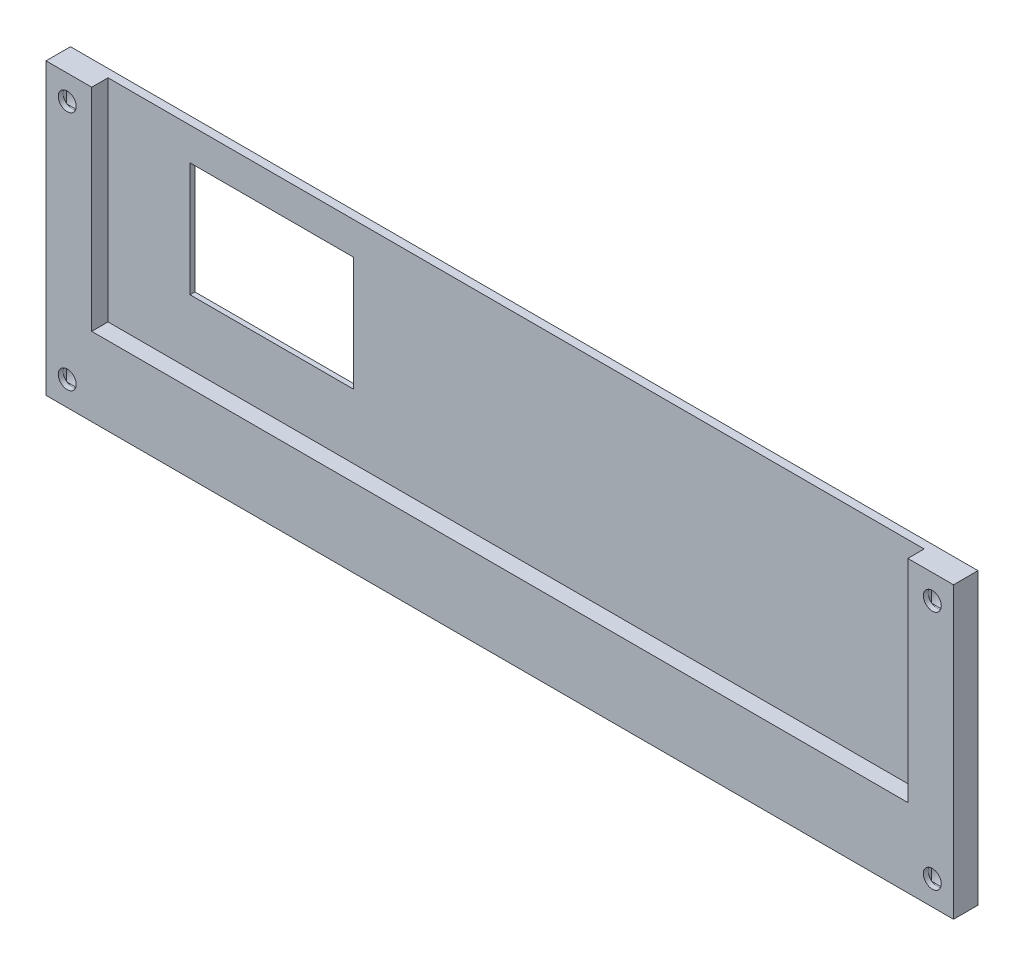
from build123d import *

# Parameters (mm, degrees)
SKETCH1_W                       = 112
SKETCH1_H                       = 35.5
BOSS_EXTRUDE1_DEPTH             = 1
SKETCH2_W                       = 6
SKETCH2_H                       = 6
BOSS_EXTRUDE2_DEPTH             = 2
SKETCH3_R                       = 1.1
CUT_EXTRUDE1_DEPTH              = 4
SKETCH4_R                       = 2
CUT_EXTRUDE2_DEPTH              = 2
SKETCH5_W                       = 20
SKETCH5_H                       = 14
CUT_EXTRUDE3_DEPTH              = 4
CHAMFER1_SIZE                   = 0.4
CUT_EXTRUDE4_DEPTH              = 0.2
SKETCH7_W                       = 2.2
SKETCH7_H                       = 2.2
CUT_EXTRUDE5_DEPTH              = 0.2
MIRROR2_COPY_1_DEPTH            = 0.2
MIRROR2_COPY_2_SKETCH_W         = 2.2
MIRROR2_COPY_2_SKETCH_H         = 2.2
MIRROR2_COPY_2_DEPTH            = 0.2
SKETCH8_W                       = 0.4
SKETCH8_H                       = 35.5
CUT_EXTRUDE6_DEPTH              = 3
CUT_EXTRUDE6_DEPTH_BACK         = 2
SKIZZE1_W                       = 5.6
SKIZZE1_H                       = 23.5
AUFSATZ_LINEAR_AUSTRAGEN1_DEPTH = 2


with BuildPart() as part:
    # Sketch1 → Boss-Extrude1 (new body)
    with BuildSketch(Plane.XY):
        Rectangle(SKETCH1_W, SKETCH1_H)
    extrude(amount=BOSS_EXTRUDE1_DEPTH)

    # Sketch2 → Boss-Extrude2 (add)
    with BuildSketch(Plane.XY.offset(1)):
        with Locations((-53, 14.75)):
            Rectangle(SKETCH2_W, SKETCH2_H)
        with Locations((-53, -14.75)):
            Rectangle(SKETCH2_W, SKETCH2_H)
        with Locations((53, -14.75)):
            Rectangle(SKETCH2_W, SKETCH2_H)
        with Locations((53, 14.75)):
            Rectangle(SKETCH2_W, SKETCH2_H)
    extrude(amount=BOSS_EXTRUDE2_DEPTH)

    # Sketch3 → Cut-Extrude1 (cut, through all)
    with BuildSketch(Plane.XY.offset(3)):
        with Locations((-53, 14.75)):
            Circle(SKETCH3_R)
        with Locations((-53, -14.75)):
            Circle(SKETCH3_R)
        with Locations((53, -14.75)):
            Circle(SKETCH3_R)
        with Locations((53, 14.75)):
            Circle(SKETCH3_R)
    extrude(amount=-CUT_EXTRUDE1_DEPTH, mode=Mode.SUBTRACT)

    # Sketch4 → Cut-Extrude2 (cut)
    with BuildSketch(Plane(origin=(0, 0, 0), x_dir=(-1, 0, 0), z_dir=(0, 0, -1))):
        with Locations((-53, 14.75)):
            Circle(SKETCH4_R)
        with Locations((-53, -14.75)):
            Circle(SKETCH4_R)
        with Locations((53, 14.75)):
            Circle(SKETCH4_R)
        with Locations((53, -14.75)):
            Circle(SKETCH4_R)
    extrude(amount=-CUT_EXTRUDE2_DEPTH, mode=Mode.SUBTRACT)

    # Sketch5 → Cut-Extrude3 (cut, through all)
    with BuildSketch(Plane(origin=(0, 0, 0), x_dir=(-1, 0, 0), z_dir=(0, 0, -1))):
        with Locations((29.95, 6.75)):
            Rectangle(SKETCH5_W, SKETCH5_H)
    extrude(amount=-CUT_EXTRUDE3_DEPTH, mode=Mode.SUBTRACT)

    # Chamfer1
    chamfer1_edges = [part.edges().sort_by_distance(p)[0] for p in [
        (-39.95, 6.75, 0),
        (-29.95, 13.75, 0),
        (-19.95, 6.75, 0),
        (-29.95, -0.25, 0),
    ]]
    chamfer(chamfer1_edges, length=CHAMFER1_SIZE)

    # Sketch6 → Cut-Extrude4 (cut)
    with BuildSketch(Plane(origin=(0, 0, 2), x_dir=(-1, 0, 0), z_dir=(0, 0, -1))):
        with BuildLine():
            Line((-54.1, 13.079670691), (-54.1, 16.420329309))
            ThreePointArc((-54.1, 16.420329309), (-53, 16.75), (-51.9, 16.420329309))
            Line((-51.9, 16.420329309), (-51.9, 13.079670691))
            ThreePointArc((-51.9, 13.079670691), (-53, 12.75), (-54.1, 13.079670691))
        make_face()
    cut_extrude4 = extrude(amount=-CUT_EXTRUDE4_DEPTH, mode=Mode.SUBTRACT)

    # Sketch7 → Cut-Extrude5 (cut)
    with BuildSketch(Plane(origin=(0, 0, 2.2), x_dir=(-1, 0, 0), z_dir=(0, 0, -1))):
        with Locations((-53, 14.75)):
            Rectangle(SKETCH7_W, SKETCH7_H)
    cut_extrude5 = extrude(amount=-CUT_EXTRUDE5_DEPTH, mode=Mode.SUBTRACT)

    # Mirror1: Cut-Extrude4, Cut-Extrude5 across plane
    add(cut_extrude4.mirror(Plane(origin=(0, 0, 0), x_dir=(0, 0, 1), z_dir=(1, 0, 0))), mode=Mode.SUBTRACT)
    add(cut_extrude5.mirror(Plane(origin=(0, 0, 0), x_dir=(0, 0, 1), z_dir=(1, 0, 0))), mode=Mode.SUBTRACT)

    # Mirror2: Cut-Extrude4, Cut-Extrude5 across plane
    add(cut_extrude4.mirror(Plane.ZX), mode=Mode.SUBTRACT)
    add(cut_extrude5.mirror(Plane.ZX), mode=Mode.SUBTRACT)

    # Mirror2 copy 1 sketch → Mirror2 copy 1 (cut)
    with BuildSketch(Plane(origin=(0, 0, 2), x_dir=(1, 0, 0), z_dir=(0, 0, -1))):
        with BuildLine():
            Line((-54.1, 13.079670691), (-54.1, 16.420329309))
            ThreePointArc((-54.1, 16.420329309), (-53, 16.75), (-51.9, 16.420329309))
            Line((-51.9, 16.420329309), (-51.9, 13.079670691))
            ThreePointArc((-51.9, 13.079670691), (-53, 12.75), (-54.1, 13.079670691))
        make_face()
    extrude(amount=-MIRROR2_COPY_1_DEPTH, mode=Mode.SUBTRACT)

    # Mirror2 copy 2 sketch → Mirror2 copy 2 (cut)
    with BuildSketch(Plane(origin=(0, 0, 2.2), x_dir=(1, 0, 0), z_dir=(0, 0, -1))):
        with Locations((-53, 14.75)):
            Rectangle(MIRROR2_COPY_2_SKETCH_W, MIRROR2_COPY_2_SKETCH_H)
    extrude(amount=-MIRROR2_COPY_2_DEPTH, mode=Mode.SUBTRACT)

    # Sketch8 → Cut-Extrude6 (cut, two sides)
    with BuildSketch(Plane.XY.offset(1)) as cut_extrude6_sk:
        with Locations((-55.8, 0)):
            Rectangle(SKETCH8_W, SKETCH8_H)
        with Locations((55.8, 0)):
            Rectangle(SKETCH8_W, SKETCH8_H)
    extrude(amount=CUT_EXTRUDE6_DEPTH, mode=Mode.SUBTRACT)
    extrude(cut_extrude6_sk.sketch, amount=-CUT_EXTRUDE6_DEPTH_BACK, mode=Mode.SUBTRACT)

    # Skizze1 → Aufsatz-Linear austragen1 (add)
    with BuildSketch(Plane.XY.offset(1)):
        Polygon((50, -8.156810447), (-50, -8.156810447), (-50, -11.75), (-50, -17.75), (50, -17.75), (50, -11.75), align=None)
        with Locations((-52.8, 0)):
            Rectangle(SKIZZE1_W, SKIZZE1_H)
        with Locations((52.8, 0)):
            Rectangle(SKIZZE1_W, SKIZZE1_H)
    extrude(amount=AUFSATZ_LINEAR_AUSTRAGEN1_DEPTH)


solid = part.part
